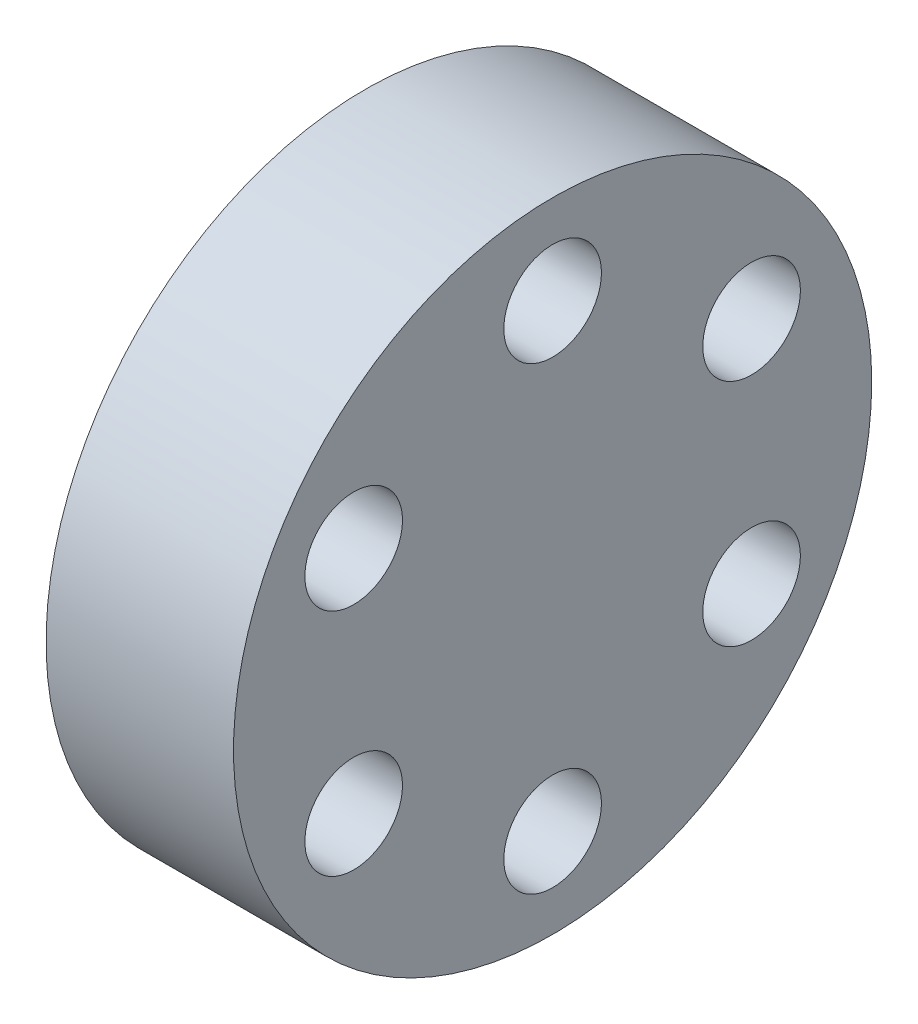
from build123d import *

# Parameters (mm, degrees)
SKETCH1_R            = 11.1125
BOSS_EXTRUDE1_DEPTH  = 6.5278
M3_CLEARANCE_HOLE1_D = 3.4


with BuildPart() as part:
    # Sketch1 → Boss-Extrude1 (new body)
    with BuildSketch(Plane(origin=(0, 0, 0), x_dir=(0, 0, -1), z_dir=(1, 0, 0))):
        Circle(SKETCH1_R)
    extrude(amount=BOSS_EXTRUDE1_DEPTH)

    # M3 Clearance Hole1 (through all)
    with Locations(Plane(origin=(6.5278, 0, 0), x_dir=(0, 0, -1), z_dir=(1, 0, 0))):
        with Locations((0, 8), (6.92820323, 4), (6.92820323, -4), (0, -8), (-6.92820323, -4), (-6.92820323, 4)):
            Hole(M3_CLEARANCE_HOLE1_D / 2)


solid = part.part
